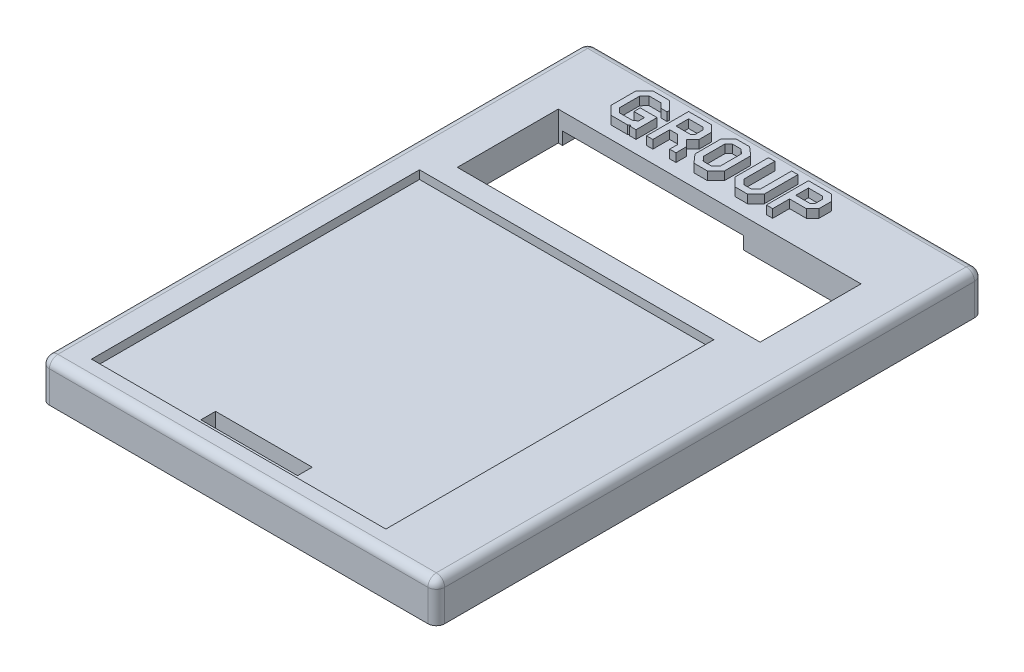
from build123d import *

# Parameters (mm, degrees)
SKETCH1_W           = 94
SKETCH1_H           = 130
BOSS_EXTRUDE1_DEPTH = 9.5
SKETCH2_W           = 90.5
SKETCH2_H           = 126.5
CUT_EXTRUDE1_DEPTH  = 2.5
SKETCH3_W           = 72
SKETCH3_H           = 24
CUT_EXTRUDE2_DEPTH  = 8
SKETCH4_W           = 70
SKETCH4_H           = 78
CUT_EXTRUDE3_DEPTH  = 2
SKETCH5_W           = 23
SKETCH5_H           = 3.5
CUT_EXTRUDE4_DEPTH  = 8.5
SKETCH6_W           = 6
SKETCH6_H           = 18
CUT_EXTRUDE5_DEPTH  = 3.5
SKETCH7_W           = 43
SKETCH7_H           = 7.5
CUT_EXTRUDE6_DEPTH  = 3
FILLET1_R           = 2
BOSS_EXTRUDE3_DEPTH = 2


with BuildPart() as part:
    # Sketch1 → Boss-Extrude1 (new body)
    with BuildSketch(Plane(origin=(0, 7, 0), x_dir=(1, 0, 0), z_dir=(0, 1, 0))):
        with Locations((47, 65)):
            Rectangle(SKETCH1_W, SKETCH1_H)
    extrude(amount=-BOSS_EXTRUDE1_DEPTH)

    # Sketch2 → Cut-Extrude1 (cut)
    with BuildSketch(Plane.XZ.offset(2.5)):
        with Locations((47, -65)):
            Rectangle(SKETCH2_W, SKETCH2_H)
    extrude(amount=-CUT_EXTRUDE1_DEPTH, mode=Mode.SUBTRACT)

    # Sketch3 → Cut-Extrude2 (cut, through all)
    with BuildSketch(Plane.XZ):
        with Locations((47, -100)):
            Rectangle(SKETCH3_W, SKETCH3_H)
    extrude(amount=-CUT_EXTRUDE2_DEPTH, mode=Mode.SUBTRACT)

    # Sketch4 → Cut-Extrude3 (cut)
    with BuildSketch(Plane(origin=(0, 7, 0), x_dir=(-1, 0, 0), z_dir=(0, 1, 0))):
        with Locations((-42, -44)):
            Rectangle(SKETCH4_W, SKETCH4_H)
    extrude(amount=-CUT_EXTRUDE3_DEPTH, mode=Mode.SUBTRACT)

    # Sketch5 → Cut-Extrude4 (cut, through all)
    with BuildSketch(Plane(origin=(0, 5, 0), x_dir=(-1, 0, 0), z_dir=(0, 1, 0))):
        with Locations((-42, -9.25)):
            Rectangle(SKETCH5_W, SKETCH5_H)
    extrude(amount=-CUT_EXTRUDE4_DEPTH, mode=Mode.SUBTRACT)

    # Sketch6 → Cut-Extrude5 (cut)
    with BuildSketch(Plane.XZ):
        with Locations((86, -100)):
            Rectangle(SKETCH6_W, SKETCH6_H)
    extrude(amount=-CUT_EXTRUDE5_DEPTH, mode=Mode.SUBTRACT)

    # Sketch7 → Cut-Extrude6 (cut)
    with BuildSketch(Plane.XZ):
        with Locations((33.5, -115.75)):
            Rectangle(SKETCH7_W, SKETCH7_H)
    extrude(amount=-CUT_EXTRUDE6_DEPTH, mode=Mode.SUBTRACT)

    # Fillet1
    fillet1_edges = [part.edges().sort_by_distance(p)[0] for p in [
        (94, 7, -65),
        (47, 7, 0),
        (0, 7, -65),
        (47, 7, -130),
        (94, 2.25, -130),
        (94, 2.25, 0),
        (0, 2.25, 0),
        (0, 2.25, -130),
    ]]
    fillet(fillet1_edges, radius=FILLET1_R)

    # Sketch10 → Boss-Extrude3 (add)
    with BuildSketch(Plane(origin=(0, 7, 0), x_dir=(1, 0, 0), z_dir=(0, 1, 0))):
        Polygon((26.5, 123), (24.5, 125), (20.5, 125), (18.5, 123), (18.5, 117), (20.5, 115), (24.5, 115), (25, 115.309128344), (25, 115), (26.5, 115), (26.5, 120), (22.5, 120), (22.5, 118.5), (25, 118.5), (25, 117.072659745), (24.07375083, 116.5), (21.121320344, 116.5), (20, 117.621320344), (20, 122.367836714), (21.110870681, 123.5), (23.878679656, 123.5), (25, 122.378679656), (26.5, 122.378679656), align=None)
        Polygon((32.378679656, 119), (30.5, 119), (30.5, 115), (29, 115), (29, 125), (34.5, 125), (36, 123.5), (36, 120.5), (34.5, 119), (36, 117.5), (36, 115), (34.5, 115), (34.5, 116.878679656), align=None)
        Polygon((30.5, 123.496173662), (30.5, 120.5), (33.882505994, 120.5), (34.5, 121.117494006), (34.5, 122.878679656), (33.882505994, 123.496173662), align=None, mode=Mode.SUBTRACT)
        Polygon((43.5, 125), (45.5, 123.276052985), (45.5, 117.021376869), (43.5, 115), (40.272028005, 115), (38.5, 117.021376869), (38.5, 123.276052985), (40.272028005, 125), align=None)
        Polygon((42.942743976, 123.5), (44, 122.588673317), (44, 117.638031489), (42.874003649, 116.5), (40.951839055, 116.5), (40, 117.585775983), (40, 122.642614002), (40.881298547, 123.5), align=None, mode=Mode.SUBTRACT)
        Polygon((48, 117), (50, 115), (53, 115), (55, 117), (55, 125), (53.5, 125), (53.5, 123.5), (53.5, 117.621320344), (52.378679656, 116.5), (50.621320344, 116.5), (49.5, 117.621320344), (49.5, 123.5), (49.5, 125), (48, 125), align=None)
        Polygon((63, 119), (59, 119), (59, 115), (57.5, 115), (57.5, 125), (63, 125), (64.5, 123.5), (64.5, 120.5), align=None)
        Polygon((59, 123.5), (59, 120.5), (62.378679656, 120.5), (63, 121.121320344), (63, 122.878679656), (62.378679656, 123.5), align=None, mode=Mode.SUBTRACT)
    extrude(amount=BOSS_EXTRUDE3_DEPTH)


solid = part.part
